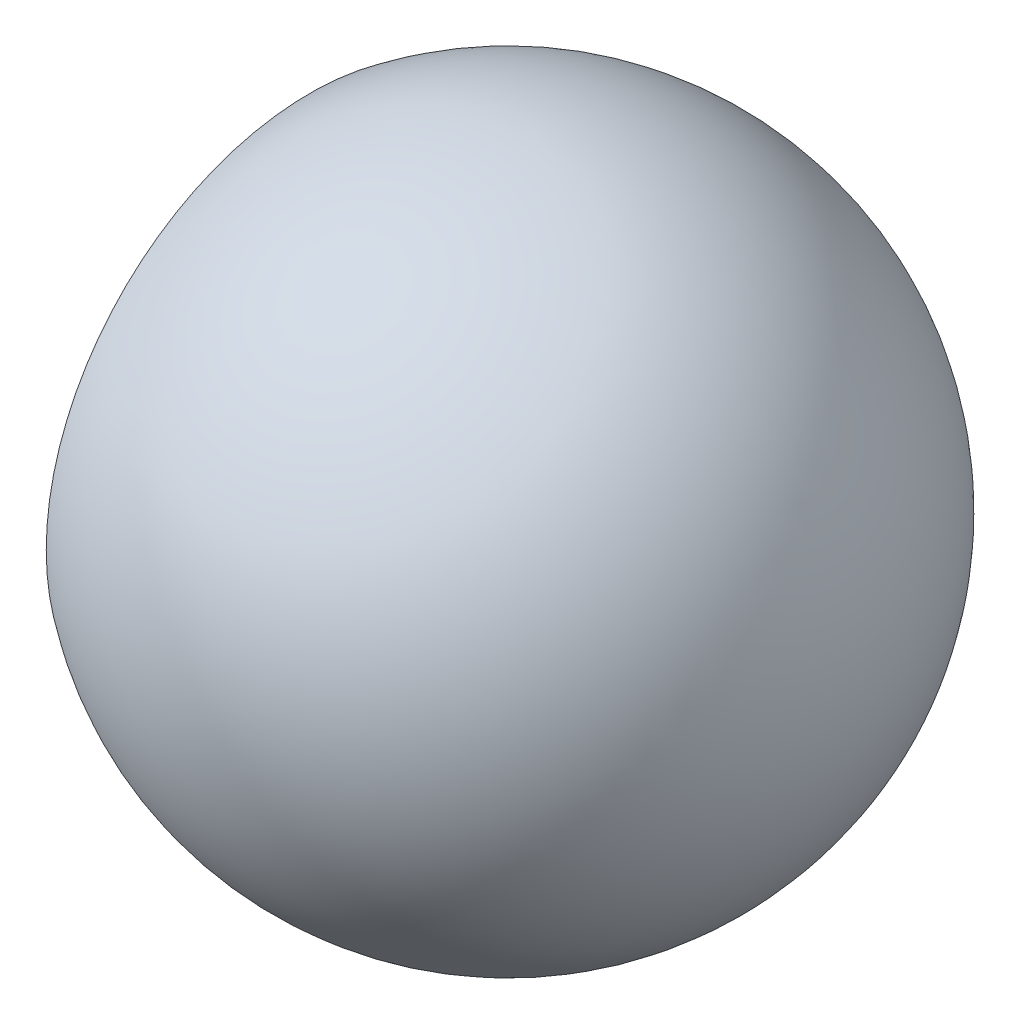
from build123d import *


with BuildPart() as part:
    # Эскиз5 → Повернуть2 (revolve)
    with BuildSketch(Plane.XY):
        with BuildLine():
            Line((0, 0), (10, 0))
            ThreePointArc((10, 0), (4.472135955, -8.94427191), (-6, -8))
            Line((-6, -8), (-6, -4))
            Line((-6, -4), (0, -4))
            Line((0, -4), (0, 0))
        make_face()
    revolve(axis=Axis((0, 0, 0), (1, 0, 0)))


solid = part.part
